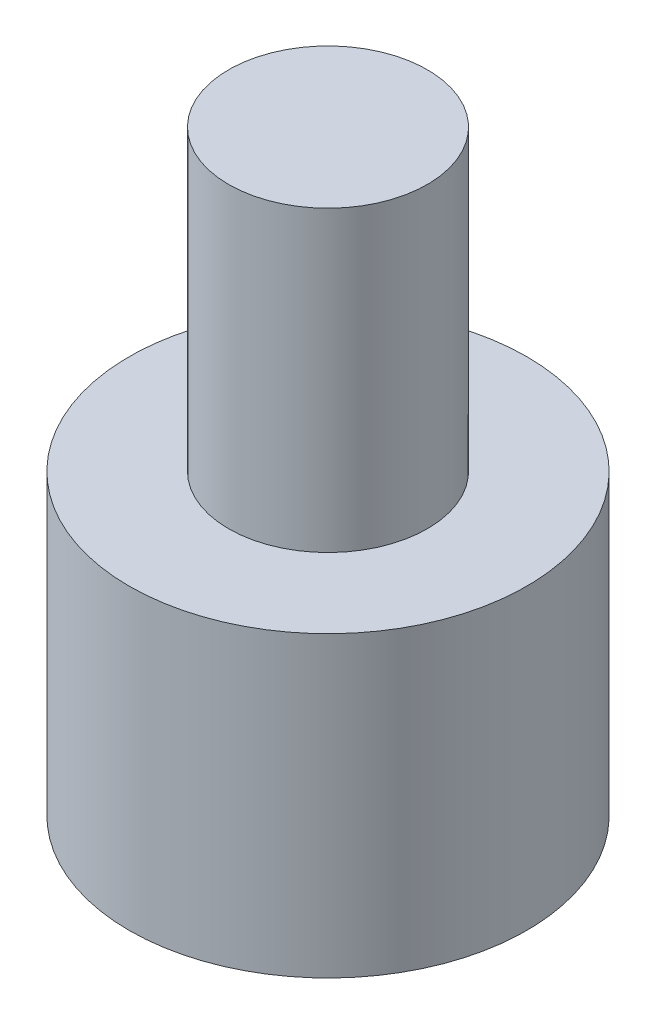
from build123d import *

# Parameters (mm, degrees)
SKETCH1_R           = 20
BOSS_EXTRUDE3_DEPTH = 30
SKETCH3_R           = 10
BOSS_EXTRUDE4_DEPTH = 30


with BuildPart() as part:
    # Sketch1 → Boss-Extrude3 (new body)
    with BuildSketch(Plane(origin=(0, 0, 0), x_dir=(1, 0, 0), z_dir=(0, 1, 0))):
        Circle(SKETCH1_R)
    extrude(amount=BOSS_EXTRUDE3_DEPTH)

    # Sketch3 → Boss-Extrude4 (add)
    with BuildSketch(Plane(origin=(0, 30, 0), x_dir=(1, 0, 0), z_dir=(0, 1, 0))):
        Circle(SKETCH3_R)
    extrude(amount=BOSS_EXTRUDE4_DEPTH)


solid = part.part
